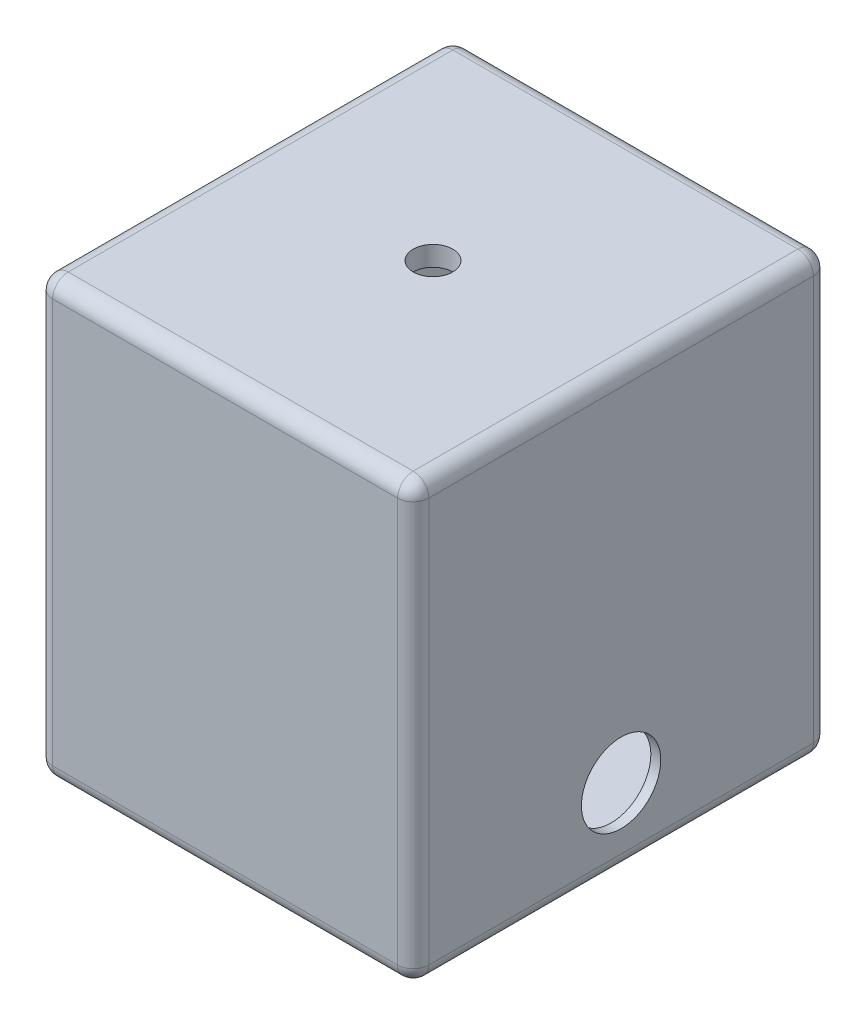
from build123d import *

# Parameters (mm, degrees)
SKETCH1_W           = 241.3
SKETCH1_H           = 266.7
BOSS_EXTRUDE1_DEPTH = 266.7
SKETCH8_W           = 228.6
SKETCH8_H           = 254
CUT_EXTRUDE4_DEPTH  = 254
SKETCH9_W           = 241.3
SKETCH9_H           = 266.7
BOSS_EXTRUDE3_DEPTH = 12.7
FILLET4_R           = 10
SKETCH10_R          = 25.4510398
CUT_EXTRUDE5_DEPTH  = 12.7
SKETCH11_R          = 12.7
CUT_EXTRUDE6_DEPTH  = 12.7


with BuildPart() as part:
    # Sketch1 → Boss-Extrude1 (new body)
    with BuildSketch(Plane(origin=(0, 0, 0), x_dir=(1, 0, 0), z_dir=(0, 1, 0))):
        Rectangle(SKETCH1_W, SKETCH1_H)
    extrude(amount=BOSS_EXTRUDE1_DEPTH)

    # Sketch8 → Cut-Extrude4 (cut)
    with BuildSketch(Plane(origin=(0, 266.7, 0), x_dir=(1, 0, 0), z_dir=(0, 1, 0))):
        Rectangle(SKETCH8_W, SKETCH8_H)
    extrude(amount=-CUT_EXTRUDE4_DEPTH, mode=Mode.SUBTRACT)

    # Sketch9 → Boss-Extrude3 (add)
    with BuildSketch(Plane(origin=(0, 266.7, 0), x_dir=(1, 0, 0), z_dir=(0, 1, 0))):
        Rectangle(SKETCH9_W, SKETCH9_H)
    extrude(amount=BOSS_EXTRUDE3_DEPTH)

    # Fillet4
    fillet4_edges = [part.edges().sort_by_distance(p)[0] for p in [
        (120.65, 279.4, 0),
        (0, 279.4, -133.35),
        (-120.65, 279.4, 0),
        (0, 279.4, 133.35),
        (0, 0, 133.35),
        (-120.65, 0, 0),
        (0, 0, -133.35),
        (120.65, 0, 0),
        (120.65, 139.7, 133.35),
        (-120.65, 139.7, 133.35),
        (-120.65, 139.7, -133.35),
        (120.65, 139.7, -133.35),
    ]]
    fillet(fillet4_edges, radius=FILLET4_R)

    # Sketch10 → Cut-Extrude5 (cut)
    with BuildSketch(Plane(origin=(120.65, 0, 0), x_dir=(0, 0, -1), z_dir=(1, 0, 0))):
        with Locations((0, 49.53971752)):
            Circle(SKETCH10_R)
    extrude(amount=-CUT_EXTRUDE5_DEPTH, mode=Mode.SUBTRACT)

    # Sketch11 → Cut-Extrude6 (cut)
    with BuildSketch(Plane(origin=(0, 279.4, 0), x_dir=(1, 0, 0), z_dir=(0, 1, 0))):
        Circle(SKETCH11_R)
    extrude(amount=-CUT_EXTRUDE6_DEPTH, mode=Mode.SUBTRACT)


solid = part.part
